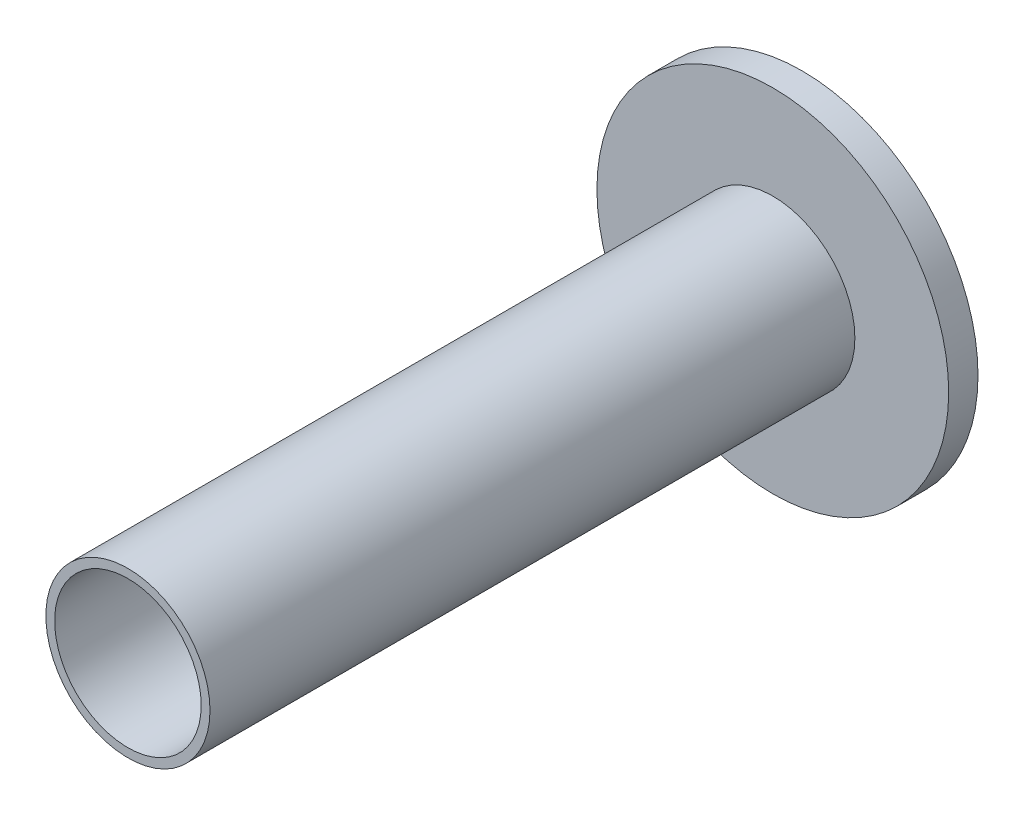
from build123d import *

# Parameters (mm, degrees)
SKETCH_1_R      = 6
EXTRUDE_1_DEPTH = 1
SKETCH_2_R      = 2.8
SKETCH_2_R_2    = 2.5
EXTRUDE_2_DEPTH = 22


with BuildPart() as part:
    # 草图1 → 凸台-拉伸1 (new body)
    with BuildSketch(Plane.XY):
        Circle(SKETCH_1_R)
    extrude(amount=EXTRUDE_1_DEPTH)

    # 草图2 → 凸台-拉伸2 (add)
    with BuildSketch(Plane.XY.offset(1)):
        Circle(SKETCH_2_R)
        Circle(SKETCH_2_R_2, mode=Mode.SUBTRACT)
    extrude(amount=EXTRUDE_2_DEPTH)


solid = part.part
